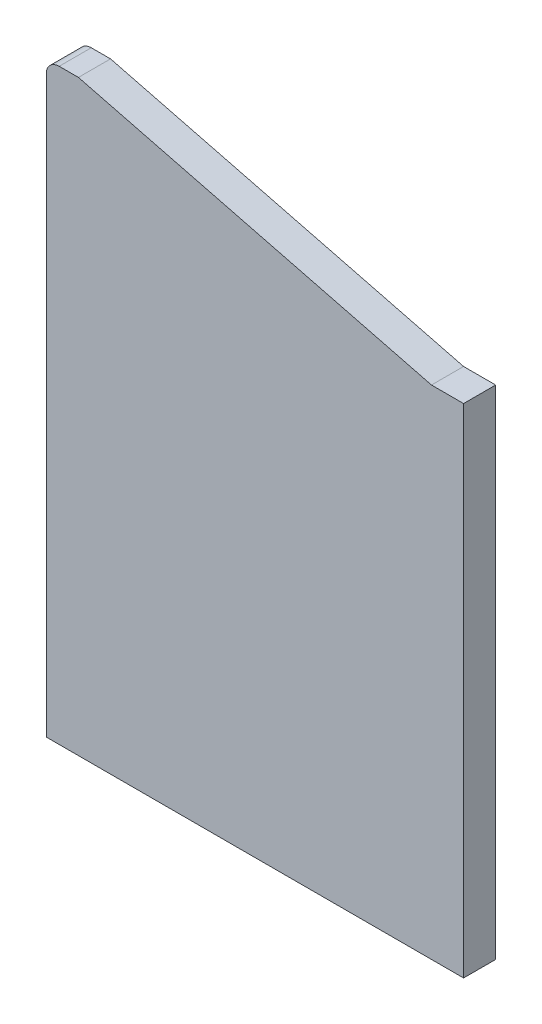
from build123d import *

# Parameters (mm, degrees)
BOSS_EXTRU_1_DEPTH = 10
CONG_1_R           = 4


with BuildPart() as part:
    # Esquisse1 → Boss.-Extru.1 (new body)
    with BuildSketch(Plane.XY):
        Polygon((0, 183), (10, 183), (120, 155), (130, 155), (130, 0), (0, 0), align=None)
    extrude(amount=BOSS_EXTRU_1_DEPTH)

    # Congé1
    cong_1_edges = [part.edges().sort_by_distance(p)[0] for p in [
        (0, 183, 5),
    ]]
    fillet(cong_1_edges, radius=CONG_1_R)


solid = part.part
